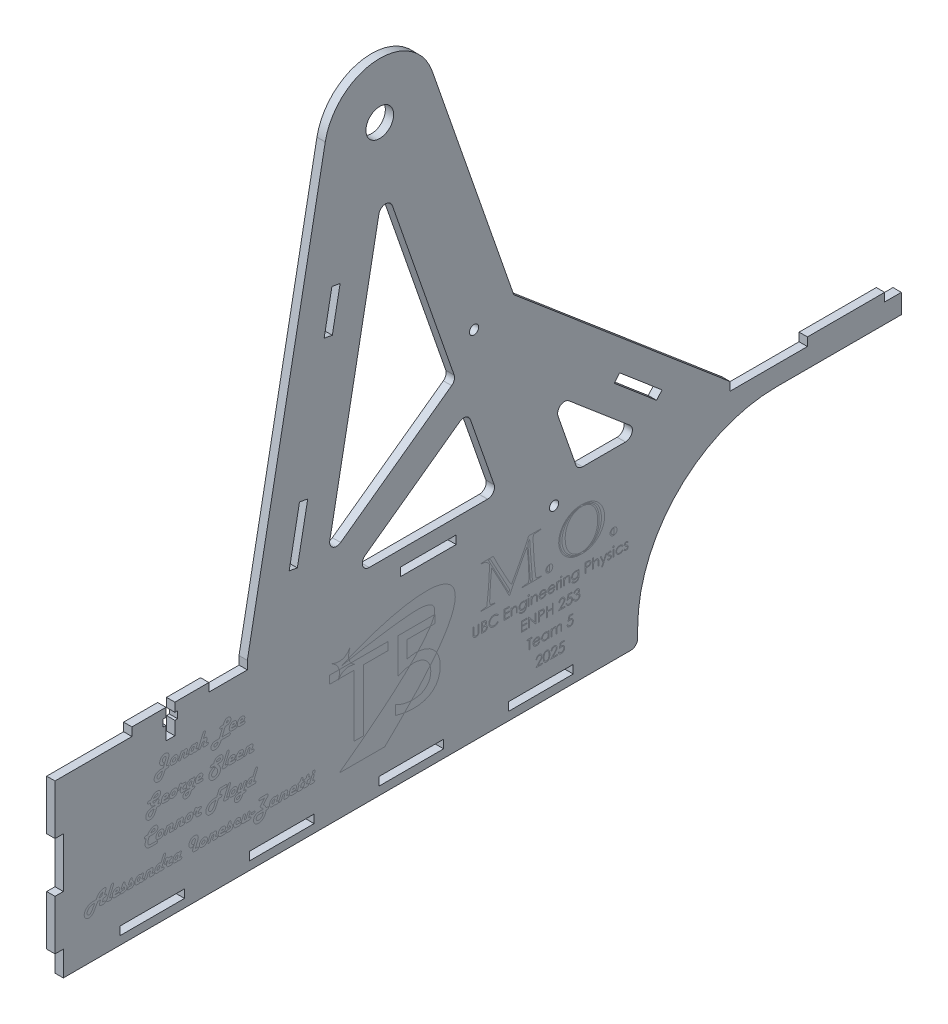
from build123d import *

# Parameters (mm, degrees)
BOSS_EXTRUDE1_DEPTH     = 3
SKETCH2_W               = 27.727272727
SKETCH2_H               = 3
SKETCH2_W_2             = 3
SKETCH2_H_2             = 18
SKETCH2_H_3             = 9
SKETCH2_W_3             = 23.343342349
SKETCH2_W_4             = 23.34334235
SKETCH2_W_5             = 6
CUT_EXTRUDE1_DEPTH      = 1
CUT_EXTRUDE1_DEPTH_BACK = 4
SKETCH3_W               = 3.2
SKETCH3_H               = 10.5
SKETCH3_W_2             = 5.2
SKETCH3_H_2             = 2.5
CUT_EXTRUDE2_DEPTH      = 1
CUT_EXTRUDE2_DEPTH_BACK = 4
FILLET1_R               = 2.5
BOSS_EXTRUDE2_DEPTH     = 3
FILLET2_R               = 2.5
SKETCH6_R               = 5
SKETCH6_R_2             = 1.65
CUT_EXTRUDE5_DEPTH      = 1
CUT_EXTRUDE5_DEPTH_BACK = 4
SKETCH8_R               = 10
SKETCH8_W               = 5
SKETCH8_H               = 1
CUT_EXTRUDE6_DEPTH      = 4
CUT_EXTRUDE6_DEPTH_BACK = 1
SKETCH8_4_R             = 10
SKETCH8_4_W             = 5
SKETCH8_4_H             = 1
BOSS_EXTRUDE4_DEPTH     = 3
SKETCH9_W               = 20
SKETCH9_H               = 3
CUT_EXTRUDE7_DEPTH      = 4
CUT_EXTRUDE7_DEPTH_BACK = 1
SKETCH10_W              = 27.840909091
SKETCH10_H              = 3
CUT_EXTRUDE8_DEPTH      = 4
CUT_EXTRUDE8_DEPTH_BACK = 1


with BuildPart() as part:
    # Sketch1 → Boss-Extrude1 (new body)
    with BuildSketch(Plane(origin=(0, 0, 0), x_dir=(0, 0, -1), z_dir=(1, 0, 0))):
        with BuildLine():
            Line((-152.5, 33), (152.5, 33))
            Line((152.5, 33), (152.5, 23))
            Line((152.5, 23), (107.5, 23))
            ThreePointArc((107.5, 23), (72.144660941, 8.355339059), (57.5, -27))
            Line((57.5, -27), (57.5, -33))
            Line((57.5, -33), (-152.5, -33))
            Line((-152.5, -33), (-152.5, 33))
        make_face()
    extrude(amount=BOSS_EXTRUDE1_DEPTH)

    # Sketch2 → Cut-Extrude1 (cut, two sides)
    with BuildSketch(Plane(origin=(3, 0, 0), x_dir=(0, 0, -1), z_dir=(1, 0, 0))) as cut_extrude1_sk:
        with Locations((-138.636363636, 31.5)):
            Rectangle(SKETCH2_W, SKETCH2_H)
        with Locations((-83.181818182, 31.5)):
            Rectangle(SKETCH2_W, SKETCH2_H)
        with Locations((-27.727272728, 31.5)):
            Rectangle(SKETCH2_W, SKETCH2_H)
        with Locations((-151, 3)):
            Rectangle(SKETCH2_W_2, SKETCH2_H_2)
        with Locations((-151, -28.5)):
            Rectangle(SKETCH2_W_2, SKETCH2_H_3)
        with Locations((-117.484986475, -28.5)):
            Rectangle(SKETCH2_W_3, SKETCH2_H)
        with Locations((-70.798301777, -28.5)):
            Rectangle(SKETCH2_W_3, SKETCH2_H)
        with Locations((22.575067622, -28.5)):
            Rectangle(SKETCH2_W_4, SKETCH2_H)
        with Locations((149.5, 31.5)):
            Rectangle(SKETCH2_W_5, SKETCH2_H)
        with Locations((-24.111617078, -28.5)):
            Rectangle(SKETCH2_W_3, SKETCH2_H)
    extrude(amount=CUT_EXTRUDE1_DEPTH, mode=Mode.SUBTRACT)
    extrude(cut_extrude1_sk.sketch, amount=-CUT_EXTRUDE1_DEPTH_BACK, mode=Mode.SUBTRACT)

    # Sketch3 → Cut-Extrude2 (cut, two sides)
    with BuildSketch(Plane(origin=(3, 0, 0), x_dir=(0, 0, -1), z_dir=(1, 0, 0))) as cut_extrude2_sk:
        with Locations((-110.909090909, 27.75)):
            Rectangle(SKETCH3_W, SKETCH3_H)
        with Locations((-110.909090909, 28.575)):
            Rectangle(SKETCH3_W_2, SKETCH3_H_2)
    extrude(amount=CUT_EXTRUDE2_DEPTH, mode=Mode.SUBTRACT)
    extrude(cut_extrude2_sk.sketch, amount=-CUT_EXTRUDE2_DEPTH_BACK, mode=Mode.SUBTRACT)

    # Fillet1
    fillet1_edges = [part.edges().sort_by_distance(p)[0] for p in [
        (1.5, -33, -57.5),
    ]]
    fillet(fillet1_edges, radius=FILLET1_R)

    # Sketch4 → Boss-Extrude2 (add)
    with BuildSketch(Plane(origin=(0, 0, 0), x_dir=(0, 0, -1), z_dir=(1, 0, 0))):
        with BuildLine():
            Line((-83.181818182, 33), (-83.181818182, 30))
            Line((-83.181818182, 30), (35.818181818, 30))
            Line((35.818181818, 30), (35.818181818, 33))
            Line((35.818181818, 33), (25.753026775, 61.931534749))
            Line((25.753026775, 61.931534749), (59.886459158, 33))
            Line((59.886459158, 33), (90.818181818, 33))
            Line((90.818181818, 33), (12.817635516, 99.113348651))
            Line((12.817635516, 99.113348651), (-16.565017269, 183.571584658))
            ThreePointArc((-16.565017269, 183.571584658), (-36.922973482, 196.946020133), (-55.102803407, 180.73442893))
            Line((-55.102803407, 180.73442893), (-83.181818182, 33))
        make_face()
        Polygon((-54.643252411, 49.263022537), (-34.033564648, 157.698467174), (-8.047004759, 83.002045982), align=None, mode=Mode.SUBTRACT)
        Polygon((-3.929894771, 71.167721507), (6.913219914, 40), (-46.974972009, 40), align=None, mode=Mode.SUBTRACT)
    extrude(amount=BOSS_EXTRUDE2_DEPTH)

    # Fillet2
    fillet2_edges = [part.edges().sort_by_distance(p)[0] for p in [
        (1.5, 33, -59.886459158),
        (1.5, 61.931534749, -25.753026775),
        (1.5, 33, -35.818181818),
        (1.5, 40, -6.913219914),
        (1.5, 71.167721507, 3.929894771),
        (1.5, 40, 46.974972009),
        (1.5, 49.263022537, 54.643252411),
        (1.5, 83.002045982, 8.047004759),
        (1.5, 157.698467174, 34.033564648),
    ]]
    fillet(fillet2_edges, radius=FILLET2_R)

    # Sketch6 → Cut-Extrude5 (cut, two sides)
    with BuildSketch(Plane(origin=(3, 0, 0), x_dir=(0, 0, -1), z_dir=(1, 0, 0))) as cut_extrude5_sk:
        with Locations((-35.454545455, 177)):
            Circle(SKETCH6_R)
        with Locations((-1.492946709, 95.333591431)):
            Circle(SKETCH6_R_2)
        with Locations((27.342535354, 25.993797473)):
            Circle(SKETCH6_R_2)
    extrude(amount=CUT_EXTRUDE5_DEPTH, mode=Mode.SUBTRACT)
    extrude(cut_extrude5_sk.sketch, amount=-CUT_EXTRUDE5_DEPTH_BACK, mode=Mode.SUBTRACT)

    # Sketch8 → Cut-Extrude6 (cut, two sides)
    with BuildSketch(Plane(origin=(0, 0, 0), x_dir=(0, 0, -1), z_dir=(1, 0, 0))) as cut_extrude6_sk:
        with Locations((-40, 0)):
            Circle(SKETCH8_R)
        with Locations((-5, 0)):
            Rectangle(SKETCH8_W, SKETCH8_H)
    extrude(amount=CUT_EXTRUDE6_DEPTH, mode=Mode.SUBTRACT)
    extrude(cut_extrude6_sk.sketch, amount=-CUT_EXTRUDE6_DEPTH_BACK, mode=Mode.SUBTRACT)

    # Sketch8_4 → Boss-Extrude4 (add)
    with BuildSketch(Plane(origin=(0, 0, 0), x_dir=(0, 0, -1), z_dir=(1, 0, 0))):
        with Locations((-40, 0)):
            Circle(SKETCH8_4_R)
        with Locations((-5, 0)):
            Rectangle(SKETCH8_4_W, SKETCH8_4_H)
    extrude(amount=BOSS_EXTRUDE4_DEPTH)

    # Sketch9 → Cut-Extrude7 (cut, two sides)
    with BuildSketch(Plane(origin=(0, 0, 0), x_dir=(0, 0, -1), z_dir=(1, 0, 0))) as cut_extrude7_sk:
        Polygon((-68.111670983, 53.378521315), (-64.377242053, 73.026779267), (-61.43000336, 72.466614928), (-65.16443229, 52.818356975), align=None)
        Polygon((-55.507973344, 119.691391905), (-52.707151647, 134.427585369), (-49.759912954, 133.867421029), (-52.560734651, 119.131227565), align=None)
        Polygon((64.311409407, 40.391956194), (49.054577079, 53.32366402), (50.994333253, 55.612188869), (66.251165581, 42.680481043), align=None)
        with Locations((-17.931502251, 33)):
            Rectangle(SKETCH9_W, SKETCH9_H)
    extrude(amount=CUT_EXTRUDE7_DEPTH, mode=Mode.SUBTRACT)
    extrude(cut_extrude7_sk.sketch, amount=-CUT_EXTRUDE7_DEPTH_BACK, mode=Mode.SUBTRACT)

    # Sketch10 → Cut-Extrude8 (cut, two sides)
    with BuildSketch(Plane(origin=(0, 0, 0), x_dir=(0, 0, -1), z_dir=(1, 0, 0))) as cut_extrude8_sk:
        with Locations((104.738636364, 31.5)):
            Rectangle(SKETCH10_W, SKETCH10_H)
    extrude(amount=CUT_EXTRUDE8_DEPTH, mode=Mode.SUBTRACT)
    extrude(cut_extrude8_sk.sketch, amount=-CUT_EXTRUDE8_DEPTH_BACK, mode=Mode.SUBTRACT)


solid = part.part
